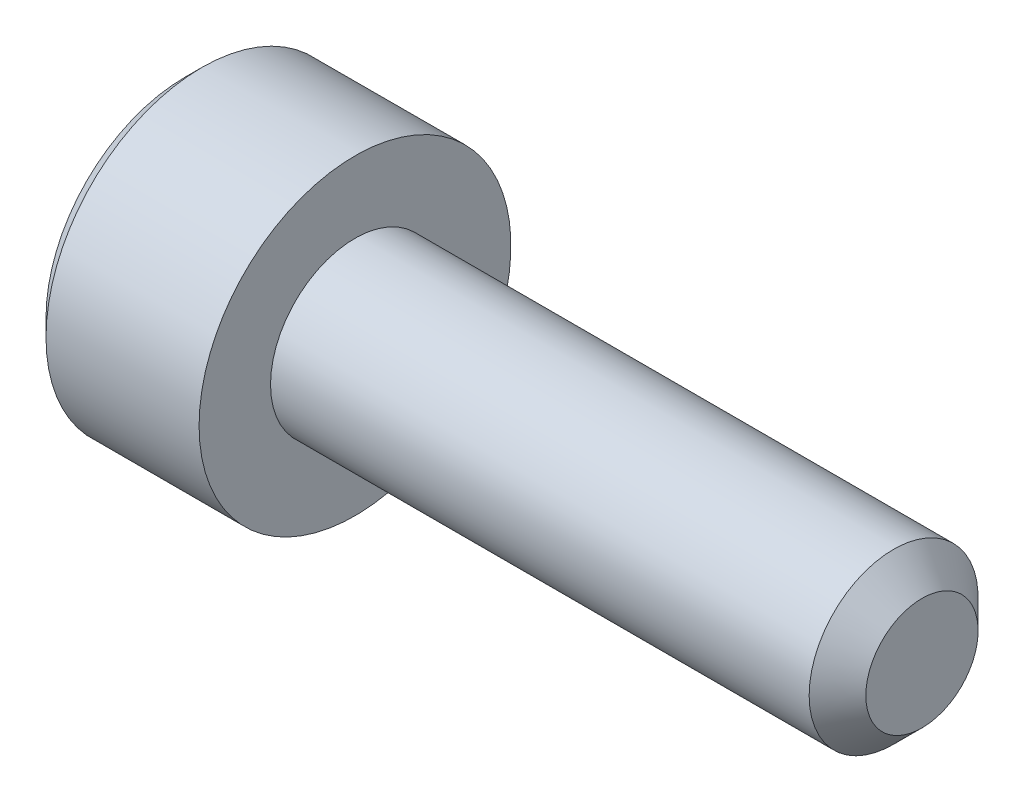
from build123d import *

# Parameters (mm, degrees)
CHAMFER1_SIZE      = 0.5
CHAMFER2_SIZE      = 0.3
CUT_EXTRUDE1_DEPTH = 2.5
CHAMFER3_SIZE      = 0.3


with BuildPart() as part:
    # Sketch1 → Revolve1 (revolve)
    with BuildSketch(Plane.XY):
        Polygon((0, 0), (0, 2.75), (3, 2.75), (3, 1.49), (13, 1.49), (13, 0), align=None)
    revolve(axis=Axis((-88.705490849, 0, 0), (1, 0, 0)))

    # Chamfer1
    chamfer1_edges = [part.edges().sort_by_distance(p)[0] for p in [
        (13, -1.49, 0),
    ]]
    chamfer(chamfer1_edges, length=CHAMFER1_SIZE)

    # Chamfer2
    chamfer2_edges = [part.edges().sort_by_distance(p)[0] for p in [
        (0, -2.75, 0),
    ]]
    chamfer(chamfer2_edges, length=CHAMFER2_SIZE)

    # Sketch3 → Cut-Extrude1 (cut)
    with BuildSketch(Plane(origin=(0, 0, 0), x_dir=(0, 0, -1), z_dir=(1, 0, 0))):
        Polygon((-1.443375673, 0), (-0.721687836, -1.25), (0.721687836, -1.25), (1.443375673, 0), (0.721687836, 1.25), (-0.721687836, 1.25), align=None)
    extrude(amount=CUT_EXTRUDE1_DEPTH, mode=Mode.SUBTRACT)

    # Chamfer3
    chamfer3_edges = [part.edges().sort_by_distance(p)[0] for p in [
        (0, 0.625, 1.082531755),
        (0, -0.625, 1.082531755),
        (0, -1.25, 0),
        (0, -0.625, -1.082531755),
        (0, 0.625, -1.082531755),
        (0, 1.25, 0),
    ]]
    chamfer(chamfer3_edges, length=CHAMFER3_SIZE)


solid = part.part
